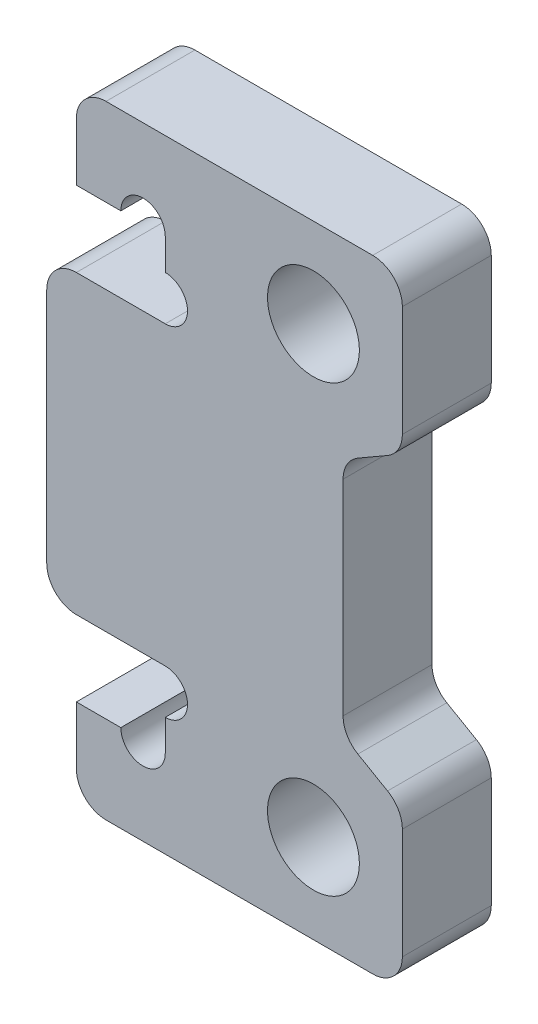
from build123d import *

# Parameters (mm, degrees)
SKETCH_1_R          = 1.55
EXTRUDE_1_DEPTH     = 1.5
SKETCH_2_W          = 3
SKETCH_2_H          = 2.95
SKETCH_2_W_2        = 4
SKETCH_2_H_2        = 10
EXTRUDE_2_DEPTH     = 3
SKETCH_3_R          = 0.75
CUT_EXTRUDE_1_DEPTH = 4
FILLET_1_R          = 1


with BuildPart() as part:
    # 草图1 → 凸台-拉伸1 (new body, symmetric)
    with BuildSketch(Plane.XY):
        Polygon((-5, 10.5), (-5, -10.5), (3, -10.5), (3, -5.190598923), (1, -4.035898385), (1, 4.035898385), (3, 5.190598923), (3, 10.5), align=None)
        with Locations((0, 7.5)):
            Circle(SKETCH_1_R, mode=Mode.SUBTRACT)
        with Locations((0, -7.5)):
            Circle(SKETCH_1_R, mode=Mode.SUBTRACT)
    extrude(amount=EXTRUDE_1_DEPTH, both=True)

    # 草图2 → 凸台-拉伸2 (add)
    with BuildSketch(Plane.XY.offset(1.5)):
        with Locations((-6.5, -9.025)):
            Rectangle(SKETCH_2_W, SKETCH_2_H)
        with Locations((-7, 0)):
            Rectangle(SKETCH_2_W_2, SKETCH_2_H_2)
        with Locations((-6.5, 9.025)):
            Rectangle(SKETCH_2_W, SKETCH_2_H)
    extrude(amount=-EXTRUDE_2_DEPTH)

    # 草图3 → 切除-拉伸1 (cut, through all)
    with BuildSketch(Plane.XY.offset(1.5)):
        with Locations((-5.75, 7.55)):
            Circle(SKETCH_3_R)
        with Locations((-5, 5.75)):
            Circle(SKETCH_3_R)
        with Locations((-5, -5.75)):
            Circle(SKETCH_3_R)
        with Locations((-5.75, -7.55)):
            Circle(SKETCH_3_R)
    extrude(amount=-CUT_EXTRUDE_1_DEPTH, mode=Mode.SUBTRACT)

    # 圆角1
    fillet_1_edges = [part.edges().sort_by_distance(p)[0] for p in [
        (3, 10.5, 0),
        (3, 5.190598923, 0),
        (1, 4.035898385, 0),
        (1, -4.035898385, 0),
        (3, -5.190598923, 0),
        (3, -10.5, 0),
        (-8, 10.5, 0),
        (-8, -10.5, 0),
        (-9, 5, 0),
        (-9, -5, 0),
    ]]
    fillet(fillet_1_edges, radius=FILLET_1_R)


solid = part.part
